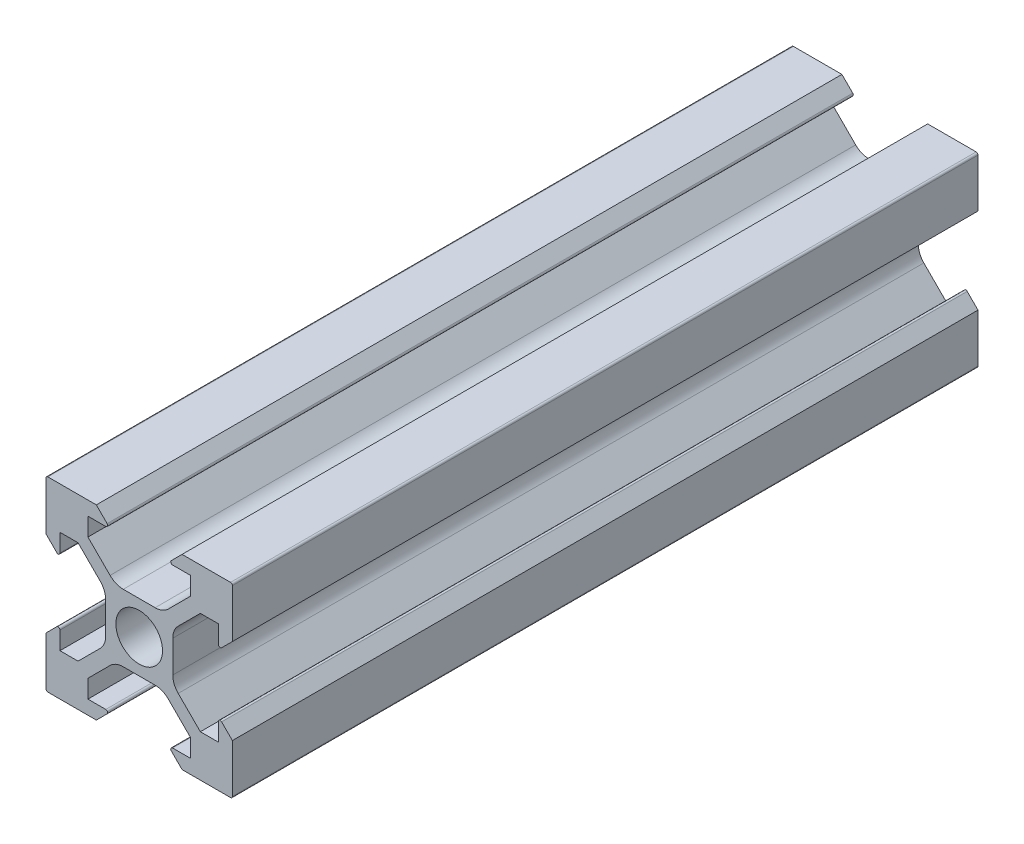
from build123d import *

# Parameters (mm, degrees)
ESBO_O1_R                = 2.5
RESSALTO_EXTRUS_O1_DEPTH = 80


with BuildPart() as part:
    # Esboço1 → Ressalto-extrusão1 (new body)
    with BuildSketch(Plane.XY):
        with BuildLine():
            Line((-4.6, -10), (-9.8, -10))
            ThreePointArc((-9.8, -10), (-9.941421356, -9.941421356), (-10, -9.8))
            Line((-10, -9.8), (-10, -4.6))
            Line((-10, -4.6), (-8.841421356, -3.441421356))
            ThreePointArc((-8.841421356, -3.441421356), (-8.623463314, -3.398066806), (-8.5, -3.582842712))
            Line((-8.5, -3.582842712), (-8.5, -5.5))
            Line((-8.5, -5.5), (-6.560660172, -5.5))
            Line((-6.560660172, -5.5), (-4.185786438, -3.125126266))
            ThreePointArc((-4.185786438, -3.125126266), (-3.752240935, -2.476279568), (-3.6, -1.710912703))
            Line((-3.6, -1.710912703), (-3.6, 1.710912703))
            ThreePointArc((-3.6, 1.710912703), (-3.752240935, 2.476279568), (-4.185786438, 3.125126266))
            Line((-4.185786438, 3.125126266), (-6.560660172, 5.5))
            Line((-6.560660172, 5.5), (-8.5, 5.5))
            Line((-8.5, 5.5), (-8.5, 3.582842712))
            ThreePointArc((-8.5, 3.582842712), (-8.623463314, 3.398066806), (-8.841421356, 3.441421356))
            Line((-8.841421356, 3.441421356), (-10, 4.6))
            Line((-10, 4.6), (-10, 9.8))
            ThreePointArc((-10, 9.8), (-9.941421356, 9.941421356), (-9.8, 10))
            Line((-9.8, 10), (-4.6, 10))
            Line((-4.6, 10), (-3.441421356, 8.841421356))
            ThreePointArc((-3.441421356, 8.841421356), (-3.398066806, 8.623463314), (-3.582842712, 8.5))
            Line((-3.582842712, 8.5), (-5.5, 8.5))
            Line((-5.5, 8.5), (-5.5, 6.560660172))
            Line((-5.5, 6.560660172), (-3.125126266, 4.185786438))
            ThreePointArc((-3.125126266, 4.185786438), (-2.476279568, 3.752240935), (-1.710912703, 3.6))
            Line((-1.710912703, 3.6), (1.710912703, 3.6))
            ThreePointArc((1.710912703, 3.6), (2.476279568, 3.752240935), (3.125126266, 4.185786438))
            Line((3.125126266, 4.185786438), (5.5, 6.560660172))
            Line((5.5, 6.560660172), (5.5, 8.5))
            Line((5.5, 8.5), (3.582842712, 8.5))
            ThreePointArc((3.582842712, 8.5), (3.398066806, 8.623463314), (3.441421356, 8.841421356))
            Line((3.441421356, 8.841421356), (4.6, 10))
            Line((4.6, 10), (9.8, 10))
            ThreePointArc((9.8, 10), (9.941421356, 9.941421356), (10, 9.8))
            Line((10, 9.8), (10, 4.6))
            Line((10, 4.6), (8.841421356, 3.441421356))
            ThreePointArc((8.841421356, 3.441421356), (8.623463314, 3.398066806), (8.5, 3.582842712))
            Line((8.5, 3.582842712), (8.5, 5.5))
            Line((8.5, 5.5), (6.560660172, 5.5))
            Line((6.560660172, 5.5), (4.185786438, 3.125126266))
            ThreePointArc((4.185786438, 3.125126266), (3.752240935, 2.476279568), (3.6, 1.710912703))
            Line((3.6, 1.710912703), (3.6, -1.710912703))
            ThreePointArc((3.6, -1.710912703), (3.752240935, -2.476279568), (4.185786438, -3.125126266))
            Line((4.185786438, -3.125126266), (6.560660172, -5.5))
            Line((6.560660172, -5.5), (8.5, -5.5))
            Line((8.5, -5.5), (8.5, -3.582842712))
            ThreePointArc((8.5, -3.582842712), (8.623463314, -3.398066806), (8.841421356, -3.441421356))
            Line((8.841421356, -3.441421356), (10, -4.6))
            Line((10, -4.6), (10, -9.8))
            ThreePointArc((10, -9.8), (9.941421356, -9.941421356), (9.8, -10))
            Line((9.8, -10), (4.6, -10))
            Line((4.6, -10), (3.441421356, -8.841421356))
            ThreePointArc((3.441421356, -8.841421356), (3.398066806, -8.623463314), (3.582842712, -8.5))
            Line((3.582842712, -8.5), (5.5, -8.5))
            Line((5.5, -8.5), (5.5, -6.560660172))
            Line((5.5, -6.560660172), (3.125126266, -4.185786438))
            ThreePointArc((3.125126266, -4.185786438), (2.476279568, -3.752240935), (1.710912703, -3.6))
            Line((1.710912703, -3.6), (-1.710912703, -3.6))
            ThreePointArc((-1.710912703, -3.6), (-2.476279568, -3.752240935), (-3.125126266, -4.185786438))
            Line((-3.125126266, -4.185786438), (-5.5, -6.560660172))
            Line((-5.5, -6.560660172), (-5.5, -8.5))
            Line((-5.5, -8.5), (-3.582842712, -8.5))
            ThreePointArc((-3.582842712, -8.5), (-3.398066806, -8.623463314), (-3.441421356, -8.841421356))
            Line((-3.441421356, -8.841421356), (-4.6, -10))
        make_face()
        Circle(ESBO_O1_R, mode=Mode.SUBTRACT)
    extrude(amount=RESSALTO_EXTRUS_O1_DEPTH)


solid = part.part
